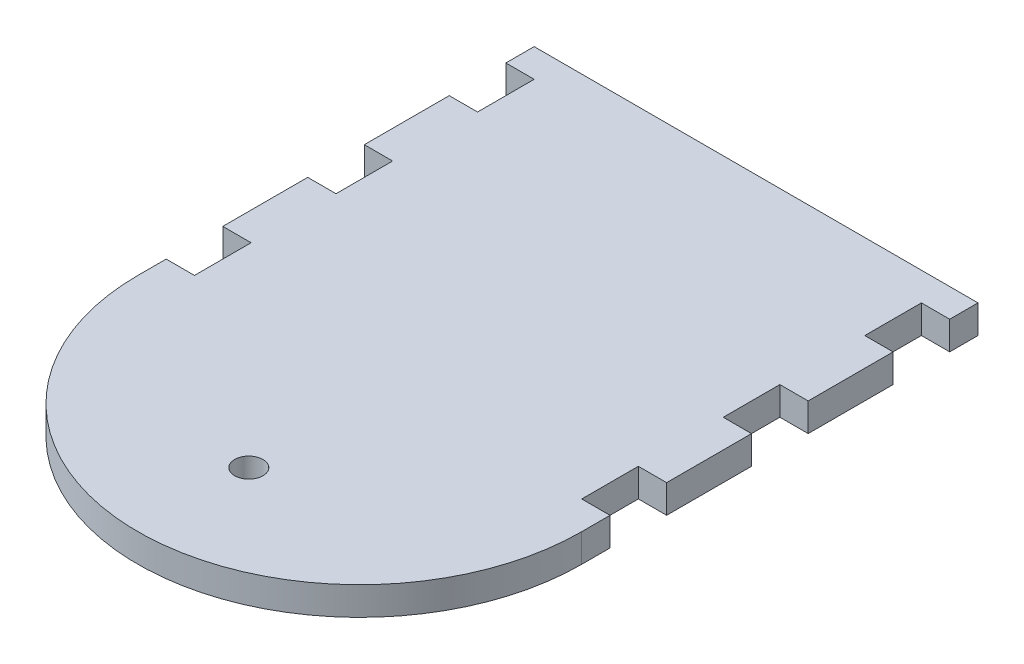
from build123d import *

# Parameters (mm, degrees)
SKETCH1_R           = 3.175
BOSS_EXTRUDE1_DEPTH = 6.35


with BuildPart() as part:
    # Sketch1 → Boss-Extrude1 (new body)
    with BuildSketch(Plane(origin=(0, 0, 0), x_dir=(1, 0, 0), z_dir=(0, 1, 0))):
        with BuildLine():
            Line((-49.784, 44.45), (49.784, 44.45))
            Line((49.784, 44.45), (49.784, 38.1))
            Line((49.784, 38.1), (43.434, 38.1))
            Line((43.434, 38.1), (43.434, 25.4))
            Line((43.434, 25.4), (49.784, 25.4))
            Line((49.784, 25.4), (49.784, 6.35))
            Line((49.784, 6.35), (43.434, 6.35))
            Line((43.434, 6.35), (43.434, -6.35))
            Line((43.434, -6.35), (49.784, -6.35))
            Line((49.784, -6.35), (49.784, -25.4))
            Line((49.784, -25.4), (43.434, -25.4))
            Line((43.434, -25.4), (43.434, -38.1))
            Line((43.434, -38.1), (49.784, -38.1))
            Line((49.784, -38.1), (49.784, -44.45))
            ThreePointArc((49.784, -44.45), (0, -94.234), (-49.784, -44.45))
            Line((-49.784, -44.45), (-49.784, -38.1))
            Line((-49.784, -38.1), (-43.434, -38.1))
            Line((-43.434, -38.1), (-43.434, -25.4))
            Line((-43.434, -25.4), (-49.784, -25.4))
            Line((-49.784, -25.4), (-49.784, -6.35))
            Line((-49.784, -6.35), (-43.434, -6.35))
            Line((-43.434, -6.35), (-43.434, 6.35))
            Line((-43.434, 6.35), (-49.784, 6.35))
            Line((-49.784, 6.35), (-49.784, 25.4))
            Line((-49.784, 25.4), (-43.434, 25.4))
            Line((-43.434, 25.4), (-43.434, 38.1))
            Line((-43.434, 38.1), (-49.784, 38.1))
            Line((-49.784, 38.1), (-49.784, 44.45))
        make_face()
        with Locations((0, -69.342)):
            Circle(SKETCH1_R, mode=Mode.SUBTRACT)
    extrude(amount=BOSS_EXTRUDE1_DEPTH)


solid = part.part
